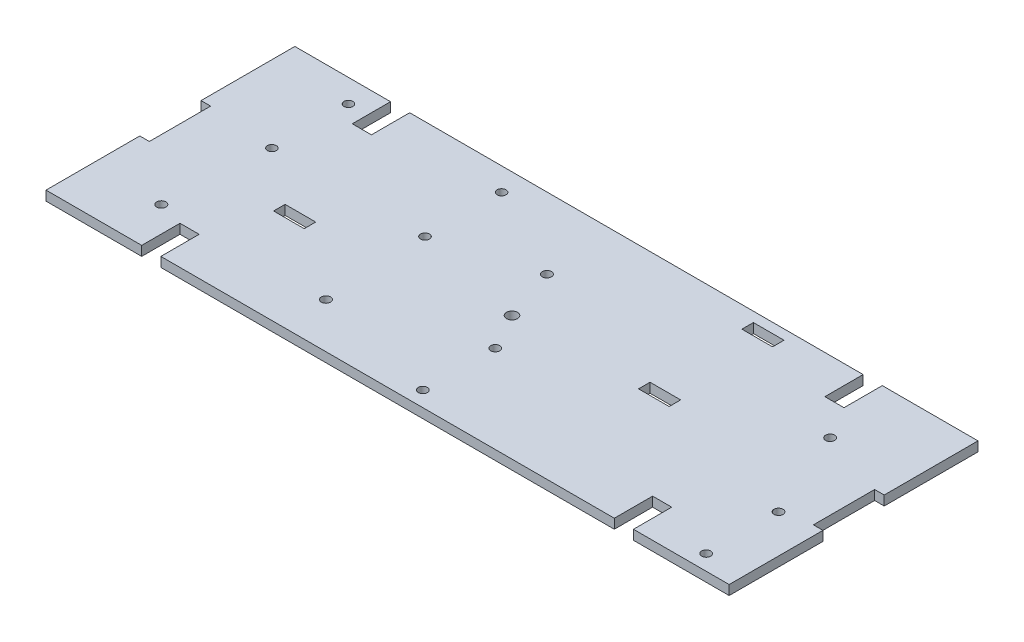
from build123d import *

# Parameters (mm, degrees)
SKETCH1_R           = 1.8288
BOSS_EXTRUDE1_DEPTH = 3.175
SKETCH3_R           = 1.5
CUT_EXTRUDE1_DEPTH  = 4.175
SKETCH4_R           = 1.4732
CUT_EXTRUDE2_DEPTH  = 4.175
SKETCH5_R           = 1.524
SKETCH5_W           = 10.16
SKETCH5_H           = 3.81
CUT_EXTRUDE3_DEPTH  = 4.175


with BuildPart() as part:
    # Sketch1 → Boss-Extrude1 (new body)
    with BuildSketch(Plane(origin=(0, 0, 0), x_dir=(1, 0, 0), z_dir=(0, 1, 0))):
        Polygon((-226.6315, 82.55), (-194.8815, 82.55), (-194.8815, 69.85), (-188.5315, 69.85), (-188.5315, 82.55), (-38.1, 82.55), (-38.1, 69.85), (-31.75, 69.85), (-31.75, 82.55), (0, 82.55), (0, 51.435), (-3.175, 51.435), (-3.175, 31.115), (0, 31.115), (0, 0), (-31.75, 0), (-31.75, 12.7), (-38.1, 12.7), (-38.1, 0), (-188.5315, 0), (-188.5315, 12.7), (-194.8815, 12.7), (-194.8815, 0), (-226.6315, 0), (-226.6315, 31.115), (-223.4565, 31.115), (-223.4565, 51.435), (-226.6315, 51.435), align=None)
        with Locations((-113.31575, 41.275)):
            Circle(SKETCH1_R, mode=Mode.SUBTRACT)
    extrude(amount=BOSS_EXTRUDE1_DEPTH)

    # Sketch3 → Cut-Extrude1 (cut, through all)
    with BuildSketch(Plane(origin=(0, 3.175, 0), x_dir=(1, 0, 0), z_dir=(0, 1, 0))):
        with Locations((-106.7, 29.08)):
            Circle(SKETCH3_R)
        with Locations((-106.7, 5.08)):
            Circle(SKETCH3_R)
        with Locations((-12.7, 5.08)):
            Circle(SKETCH3_R)
        with Locations((-12.7, 29.08)):
            Circle(SKETCH3_R)
    extrude(amount=-CUT_EXTRUDE1_DEPTH, mode=Mode.SUBTRACT)

    # Sketch4 → Cut-Extrude2 (cut, through all)
    with BuildSketch(Plane(origin=(0, 3.175, 0), x_dir=(1, 0, 0), z_dir=(0, 1, 0))):
        with Locations((-150.4315, 49.53)):
            Circle(SKETCH4_R)
        with Locations((-150.4315, 74.93)):
            Circle(SKETCH4_R)
        with Locations((-201.2315, 74.93)):
            Circle(SKETCH4_R)
        with Locations((-201.2315, 49.53)):
            Circle(SKETCH4_R)
    extrude(amount=-CUT_EXTRUDE2_DEPTH, mode=Mode.SUBTRACT)

    # Sketch5 → Cut-Extrude3 (cut, through all)
    with BuildSketch(Plane(origin=(0, 3.175, 0), x_dir=(1, 0, 0), z_dir=(0, 1, 0))):
        with Locations((-203.369556456, 14.996771974)):
            Circle(SKETCH5_R)
        with Locations((-148.759556456, 14.996771974)):
            Circle(SKETCH5_R)
        with Locations((-25.4, 58.913810593)):
            Circle(SKETCH5_R)
        with Locations((-119.38, 58.913810593)):
            Circle(SKETCH5_R)
        with Locations((-177.797598384, 33.655)):
            Rectangle(SKETCH5_W, SKETCH5_H)
        with Locations((-66.164783375, 43.089749173)):
            Rectangle(SKETCH5_W, SKETCH5_H)
        with Locations((-66.164783375, 77.379749173)):
            Rectangle(SKETCH5_W, SKETCH5_H)
    extrude(amount=-CUT_EXTRUDE3_DEPTH, mode=Mode.SUBTRACT)


solid = part.part
